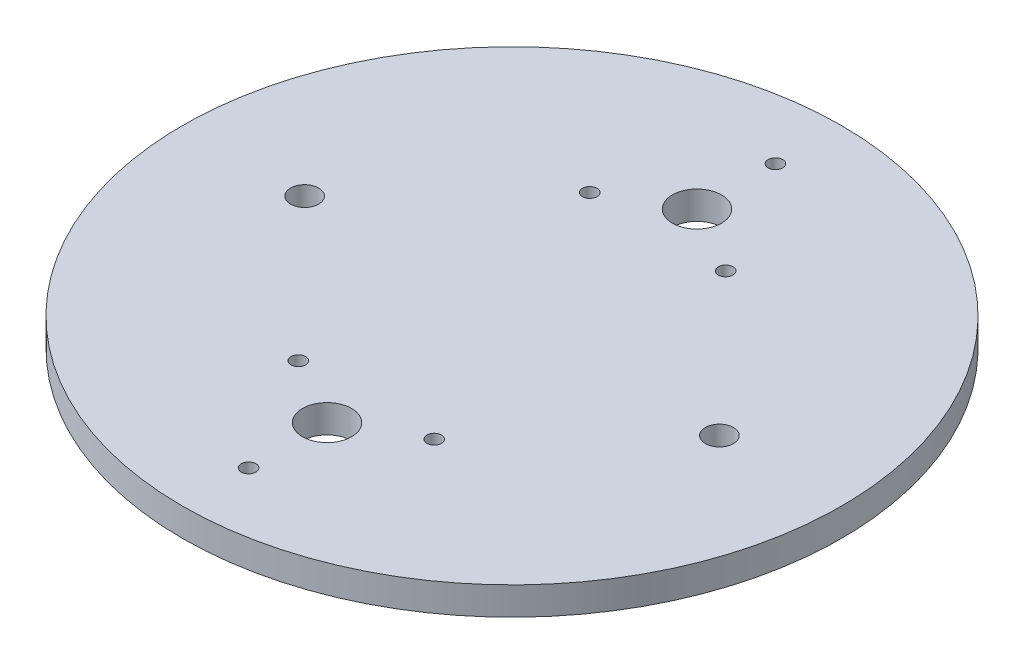
from build123d import *

# Parameters (mm, degrees)
SKETCH1_R                  = 74.676
BOSS_EXTRUDE1_DEPTH        = 6.35
SKETCH2_R                  = 1.651
SKETCH2_R_2                = 5.5626
CO2EJEC_FLANGE_HOLES_DEPTH = 6.35
SKETCH3_R                  = 3.175
F_1_4_HOLES_DEPTH          = 6.35


with BuildPart() as part:
    # Sketch1 → Boss-Extrude1 (new body)
    with BuildSketch(Plane(origin=(0, 0, 0), x_dir=(1, 0, 0), z_dir=(0, 1, 0))):
        Circle(SKETCH1_R)
    extrude(amount=BOSS_EXTRUDE1_DEPTH)

    # Sketch2 → CO2Ejec_Flange_Holes (cut)
    with BuildSketch(Plane(origin=(0, 6.35, 0), x_dir=(1, 0, 0), z_dir=(0, 1, 0))):
        with Locations((15.397931679, 33.02)):
            Circle(SKETCH2_R)
        with Locations((0, 41.91)):
            Circle(SKETCH2_R_2)
        with Locations((0, 59.69)):
            Circle(SKETCH2_R)
        with Locations((-15.397931679, 33.02)):
            Circle(SKETCH2_R)
        with Locations((0, -59.69)):
            Circle(SKETCH2_R)
        with Locations((-15.397931679, -33.02)):
            Circle(SKETCH2_R)
        with Locations((0, -41.91)):
            Circle(SKETCH2_R_2)
        with Locations((15.397931679, -33.02)):
            Circle(SKETCH2_R)
    extrude(amount=-CO2EJEC_FLANGE_HOLES_DEPTH, mode=Mode.SUBTRACT)

    # Sketch3 → 1/4 Holes (cut)
    with BuildSketch(Plane(origin=(0, 6.35, 0), x_dir=(1, 0, 0), z_dir=(0, 1, 0))):
        with Locations((-46.99, 0)):
            Circle(SKETCH3_R)
        with Locations((46.99, 0)):
            Circle(SKETCH3_R)
    extrude(amount=-F_1_4_HOLES_DEPTH, mode=Mode.SUBTRACT)


solid = part.part
